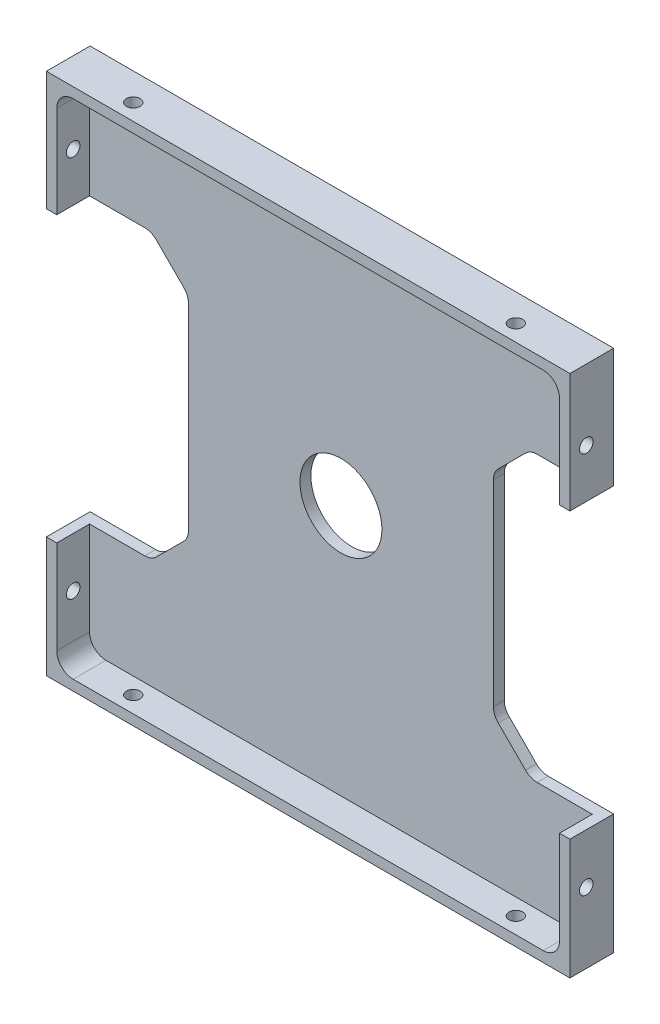
from build123d import *

# Parameters (mm, degrees)
SKETCH1_W                      = 95.8
SKETCH1_H                      = 95.8
BOSS_EXTRUDE1_DEPTH            = 8
SKETCH2_W                      = 92
SKETCH2_H                      = 92
COMPONENT_PLATFORM_DEPTH       = 6
CABLE_SLOTS_DEPTH              = 6
SKETCH4_R                      = 7.5
CENTER_MASS_CUT_DEPTH          = 6
INNER_CORNER_FILLETS_R         = 3
M3X0_5_TAPPED_HOLE1_AT_2_COUNT = 2
M3X0_5_TAPPED_HOLE1_AT_2_PITCH = 70
M3X0_5_TAPPED_HOLE2_AT_2_COUNT = 2
M3X0_5_TAPPED_HOLE2_AT_2_PITCH = 70


with BuildPart() as part:
    # Sketch1 → Boss-Extrude1 (new body)
    with BuildSketch(Plane.XY):
        Rectangle(SKETCH1_W, SKETCH1_H)
    extrude(amount=BOSS_EXTRUDE1_DEPTH)

    # Sketch2 → Component Platform (cut)
    with BuildSketch(Plane.XY.offset(8)):
        Rectangle(SKETCH2_W, SKETCH2_H)
    extrude(amount=-COMPONENT_PLATFORM_DEPTH, mode=Mode.SUBTRACT)

    # Sketch3 → Cable Slots (cut, symmetric)
    with BuildSketch(Plane.XY.offset(2)):
        with BuildLine():
            Line((-33.778679656, -25.021320344), (-28.778679656, -20.021320344))
            ThreePointArc((-28.778679656, -20.021320344), (-28.128361402, -19.048050297), (-27.9, -17.9))
            Line((-27.9, -17.9), (-27.9, 18.1))
            ThreePointArc((-27.9, 18.1), (-28.128361402, 19.248050297), (-28.778679656, 20.221320344))
            Line((-28.778679656, 20.221320344), (-33.778679656, 25.221320344))
            ThreePointArc((-33.778679656, 25.221320344), (-34.751949703, 25.871638598), (-35.9, 26.1))
            Line((-35.9, 26.1), (-47.9, 26.1))
            Line((-47.9, 26.1), (-47.9, -25.9))
            Line((-47.9, -25.9), (-35.9, -25.9))
            ThreePointArc((-35.9, -25.9), (-34.751949703, -25.671638598), (-33.778679656, -25.021320344))
        make_face()
        with BuildLine():
            Line((47.9, -25.9), (47.9, 26.1))
            Line((47.9, 26.1), (35.9, 26.1))
            ThreePointArc((35.9, 26.1), (34.751949703, 25.871638598), (33.778679656, 25.221320344))
            Line((33.778679656, 25.221320344), (28.778679656, 20.221320344))
            ThreePointArc((28.778679656, 20.221320344), (28.128361402, 19.248050297), (27.9, 18.1))
            Line((27.9, 18.1), (27.9, -17.9))
            ThreePointArc((27.9, -17.9), (28.128361402, -19.048050297), (28.778679656, -20.021320344))
            Line((28.778679656, -20.021320344), (33.778679656, -25.021320344))
            ThreePointArc((33.778679656, -25.021320344), (34.751949703, -25.671638598), (35.9, -25.9))
            Line((35.9, -25.9), (47.9, -25.9))
        make_face()
    extrude(amount=CABLE_SLOTS_DEPTH, both=True, mode=Mode.SUBTRACT)

    # Sketch4 → Center Mass Cut (cut)
    with BuildSketch(Plane.XY.offset(2)):
        Circle(SKETCH4_R)
    extrude(amount=-CENTER_MASS_CUT_DEPTH, mode=Mode.SUBTRACT)

    # Inner Corner Fillets
    inner_corner_fillets_edges = [part.edges().sort_by_distance(p)[0] for p in [
        (-46, -46, 5),
        (-46, 46, 5),
        (46, 46, 5),
        (46, -46, 5),
    ]]
    fillet(inner_corner_fillets_edges, radius=INNER_CORNER_FILLETS_R)

    # Sketch10 → M3x0.5 Tapped Hole1 (revolve, cut)
    with BuildSketch(Plane(origin=(47.9, -35, 5), x_dir=(0, 0, -1), z_dir=(0, 1, 0))):
        Polygon((0, 0), (0, 10.751075774), (1.25, 10), (1.25, 0), align=None)
    m3x0_5_tapped_hole1 = revolve(axis=Axis((54.25, -35, 5), (-1, 0, 0)), mode=Mode.SUBTRACT)

    # M3x0.5 Tapped Hole1 at 2: M3x0.5 Tapped Hole1 ×2
    with Locations(*[(0, i * M3X0_5_TAPPED_HOLE1_AT_2_PITCH, 0) for i in range(1, M3X0_5_TAPPED_HOLE1_AT_2_COUNT)]):
        add(m3x0_5_tapped_hole1, mode=Mode.SUBTRACT)

    # Sketch13 → M3x0.5 Tapped Hole2 (revolve, cut)
    with BuildSketch(Plane(origin=(-35, -47.9, 5), x_dir=(0, 0, -1), z_dir=(1, 0, 0))):
        Polygon((0, 0), (0, 10.751075774), (1.25, 10), (1.25, 0), align=None)
    m3x0_5_tapped_hole2 = revolve(axis=Axis((-35, -54.25, 5), (0, 1, 0)), mode=Mode.SUBTRACT)

    # M3x0.5 Tapped Hole2 at 2: M3x0.5 Tapped Hole2 ×2
    with Locations(*[(i * M3X0_5_TAPPED_HOLE2_AT_2_PITCH, 0, 0) for i in range(1, M3X0_5_TAPPED_HOLE2_AT_2_COUNT)]):
        add(m3x0_5_tapped_hole2, mode=Mode.SUBTRACT)

    # Mirror1: M3x0.5 Tapped Hole1 across plane
    add(m3x0_5_tapped_hole1.mirror(Plane(origin=(-0.1, 0, 0), x_dir=(0, 0, 1), z_dir=(1, 0, 0))), mode=Mode.SUBTRACT)

    # Mirror1 copy 1 sketch → Mirror1 copy 1 (revolve, cut)
    with BuildSketch(Plane(origin=(-48.1, 35, 5), x_dir=(0, 0, -1), z_dir=(0, 1, 0))):
        Polygon((0, 0), (0, -10.751075774), (1.25, -10), (1.25, 0), align=None)
    revolve(axis=Axis((-54.45, 35, 5), (-1, 0, 0)), mode=Mode.SUBTRACT)

    # Mirror2: M3x0.5 Tapped Hole2 across plane
    add(m3x0_5_tapped_hole2.mirror(Plane(origin=(0, 0.1, 0), x_dir=(0, 0, 1), z_dir=(0, -1, 0))), mode=Mode.SUBTRACT)

    # Mirror2 copy 1 sketch → Mirror2 copy 1 (revolve, cut)
    with BuildSketch(Plane(origin=(35, 48.1, 5), x_dir=(0, 0, -1), z_dir=(1, 0, 0))):
        Polygon((0, 0), (0, -10.751075774), (1.25, -10), (1.25, 0), align=None)
    revolve(axis=Axis((35, 54.45, 5), (0, 1, 0)), mode=Mode.SUBTRACT)


solid = part.part
